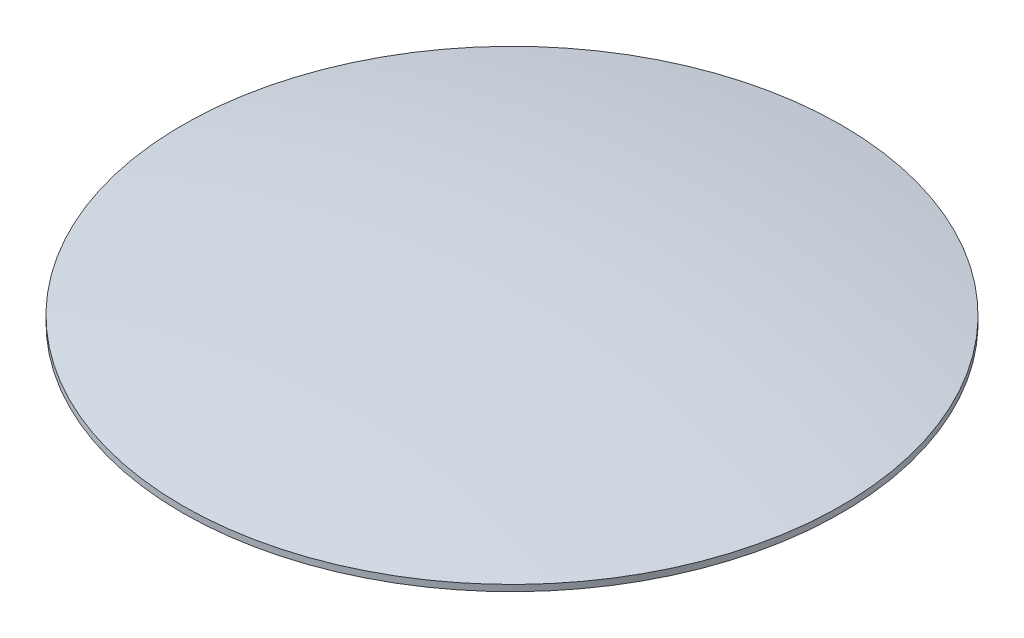
from build123d import *

# Parameters (mm, degrees)
SKETCH1_R         = 13.335
EXTRUDE1_DEPTH    = 0.254
DOME1_FACE_RADIUS = 13.335
DOME1_HEIGHT      = 1.27


with BuildPart() as part:
    # Sketch1 → Extrude1 (new body)
    with BuildSketch(Plane(origin=(0, 0, 0), x_dir=(1, 0, 0), z_dir=(0, 1, 0))):
        Circle(SKETCH1_R)
    extrude(amount=EXTRUDE1_DEPTH)

    # Dome1: a dome of height H over a round flat face of radius A is a cap of a sphere of radius (A * A + H * H) / (2 * H)
    dome1_r = (DOME1_FACE_RADIUS * DOME1_FACE_RADIUS + DOME1_HEIGHT * DOME1_HEIGHT) / (2 * DOME1_HEIGHT)
    dome1_base = Plane((0, 0.254, 0), z_dir=(0, 1, 0))
    with Locations(dome1_base.offset(DOME1_HEIGHT - dome1_r)):
        dome1_ball = Sphere(dome1_r, mode=Mode.PRIVATE)
    add(split(dome1_ball, bisect_by=dome1_base, keep=Keep.TOP, mode=Mode.PRIVATE))


solid = part.part
